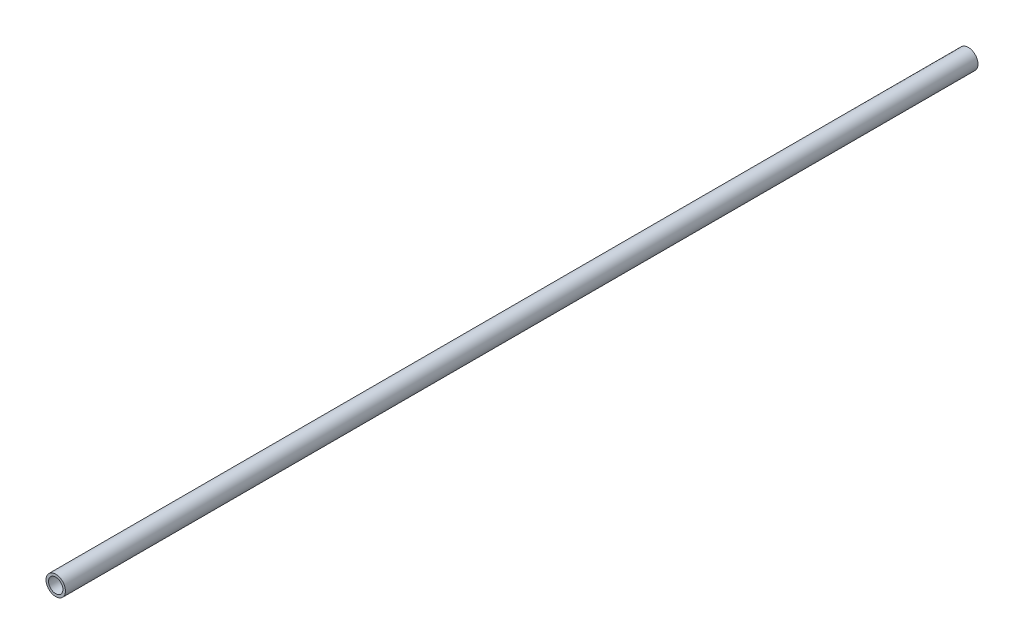
from build123d import *

# Parameters (mm, degrees)
SKETCH1_R           = 10.668
SKETCH1_R_2         = 7.8994
EXTRUDE_THIN1_DEPTH = 500


with BuildPart() as part:
    # Sketch1 → Extrude-Thin1 (new body, symmetric)
    with BuildSketch(Plane.XY):
        Circle(SKETCH1_R)
        Circle(SKETCH1_R_2, mode=Mode.SUBTRACT)
    extrude(amount=EXTRUDE_THIN1_DEPTH, both=True)


solid = part.part
